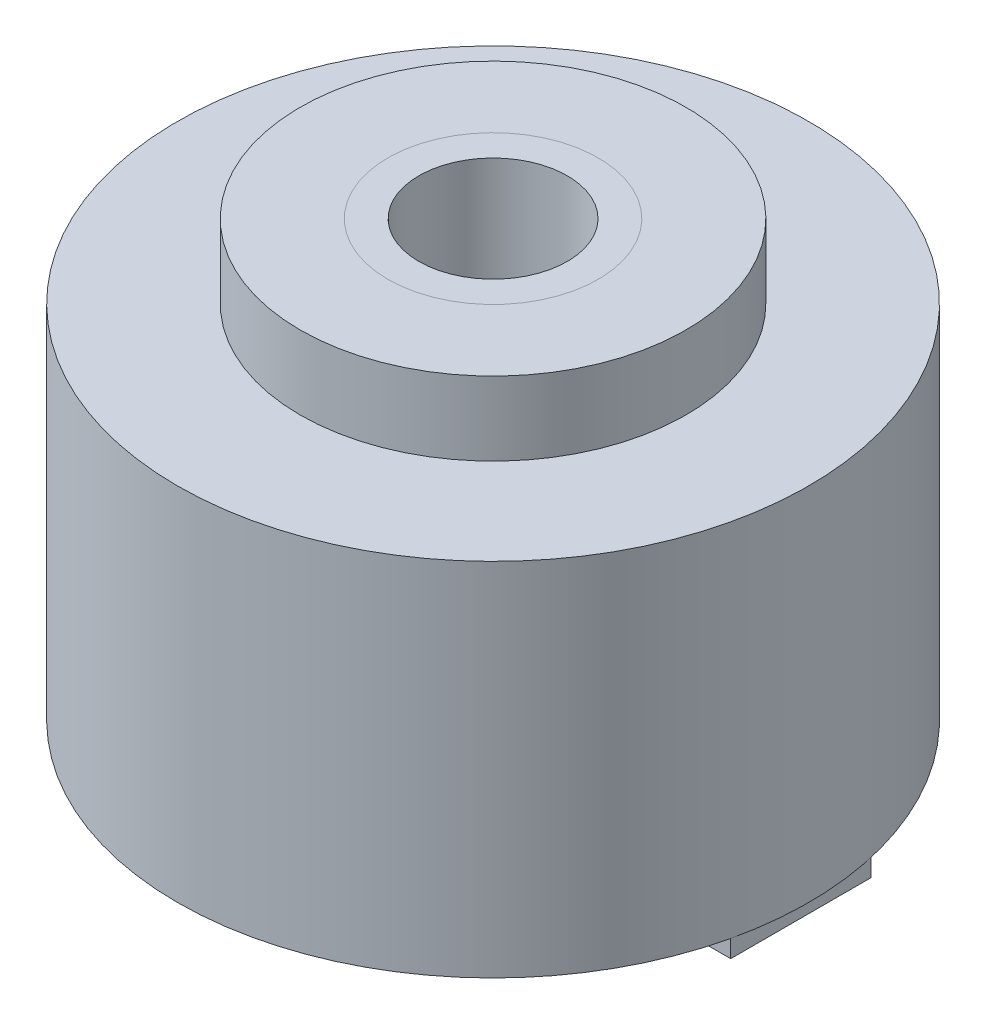
from build123d import *

# Parameters (mm, degrees)
SKETCH2_R                = 27
SKETCH2_R_2              = 6.35
BOSS_EXTRUDE1_DEPTH      = 30.861
SKETCH3_R                = 16.5
SKETCH3_R_2              = 9
BOSS_EXTRUDE2_DEPTH      = 6.3
SKETCH4_R                = 9
BOSS_EXTRUDE3_DEPTH      = 6.3
BOSS_EXTRUDE3_DEPTH_BACK = 31.861
SKETCH5_R                = 6.35
CUT_EXTRUDE1_DEPTH       = 39.161
BOSS_EXTRUDE4_DEPTH      = 1.5


with BuildPart() as part:
    # Sketch2 → Boss-Extrude1 (new body)
    with BuildSketch(Plane(origin=(0, 0, 0), x_dir=(1, 0, 0), z_dir=(0, 1, 0))):
        Circle(SKETCH2_R)
        Circle(SKETCH2_R_2, mode=Mode.SUBTRACT)
    extrude(amount=BOSS_EXTRUDE1_DEPTH)

    # Sketch3 → Boss-Extrude2 (add)
    with BuildSketch(Plane(origin=(0, 30.861, 0), x_dir=(1, 0, 0), z_dir=(0, 1, 0))):
        Circle(SKETCH3_R)
        Circle(SKETCH3_R_2, mode=Mode.SUBTRACT)
    extrude(amount=BOSS_EXTRUDE2_DEPTH)


with BuildPart() as body_2:
    # Sketch4 → Boss-Extrude3 (new body, two sides)
    with BuildSketch(Plane(origin=(0, 30.861, 0), x_dir=(1, 0, 0), z_dir=(0, 1, 0))) as boss_extrude3_sk:
        Circle(SKETCH4_R)
    extrude(amount=BOSS_EXTRUDE3_DEPTH)
    extrude(boss_extrude3_sk.sketch, amount=-BOSS_EXTRUDE3_DEPTH_BACK)

    # Sketch5 → Cut-Extrude1 (cut, through all)
    with BuildSketch(Plane(origin=(0, 37.161, 0), x_dir=(1, 0, 0), z_dir=(0, 1, 0))):
        Circle(SKETCH5_R)
    extrude(amount=-CUT_EXTRUDE1_DEPTH, mode=Mode.SUBTRACT)


with BuildPart() as body_3:
    # Sketch6 → Boss-Extrude4 (new body)
    with BuildSketch(Plane.XZ):
        with BuildLine():
            Line((26.324893162, -6), (26.324893162, 6))
            Line((26.324893162, 6), (9.179893162, 6))
            Line((9.179893162, 6), (9.179893162, 3))
            ThreePointArc((9.179893162, 3), (12.179893162, 0), (9.179893162, -3))
            Line((9.179893162, -3), (9.179893162, -6))
            Line((9.179893162, -6), (26.324893162, -6))
        make_face()
    extrude(amount=BOSS_EXTRUDE4_DEPTH)


solid = Compound([part.part, body_2.part, body_3.part])
